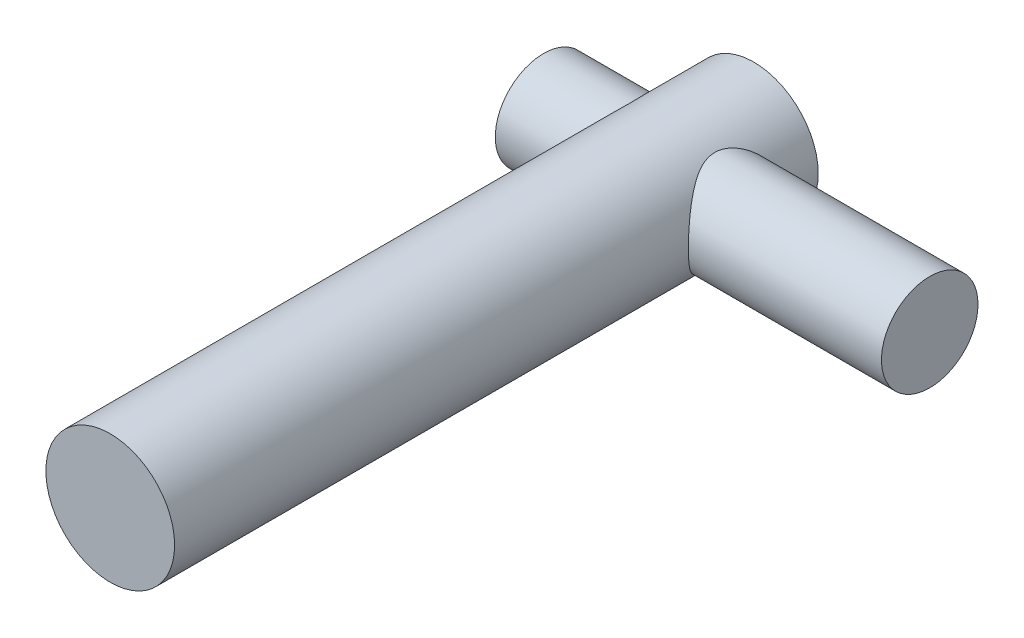
from build123d import *

# Parameters (mm, degrees)
CROQUIS1_R              = 10
SALIENTE_EXTRUIR1_DEPTH = 100
CROQUIS2_R              = 7.5
SALIENTE_EXTRUIR2_DEPTH = 30


with BuildPart() as part:
    # Croquis1 → Saliente-Extruir1 (new body)
    with BuildSketch(Plane.XY):
        Circle(CROQUIS1_R)
    extrude(amount=-SALIENTE_EXTRUIR1_DEPTH)

    # Croquis2 → Saliente-Extruir2 (add, symmetric)
    with BuildSketch(Plane(origin=(10, 0, 0), x_dir=(0, 0, -1), z_dir=(1, 0, 0))):
        with Locations((87.3235533, 0)):
            Circle(CROQUIS2_R)
    extrude(amount=SALIENTE_EXTRUIR2_DEPTH, both=True)


solid = part.part
